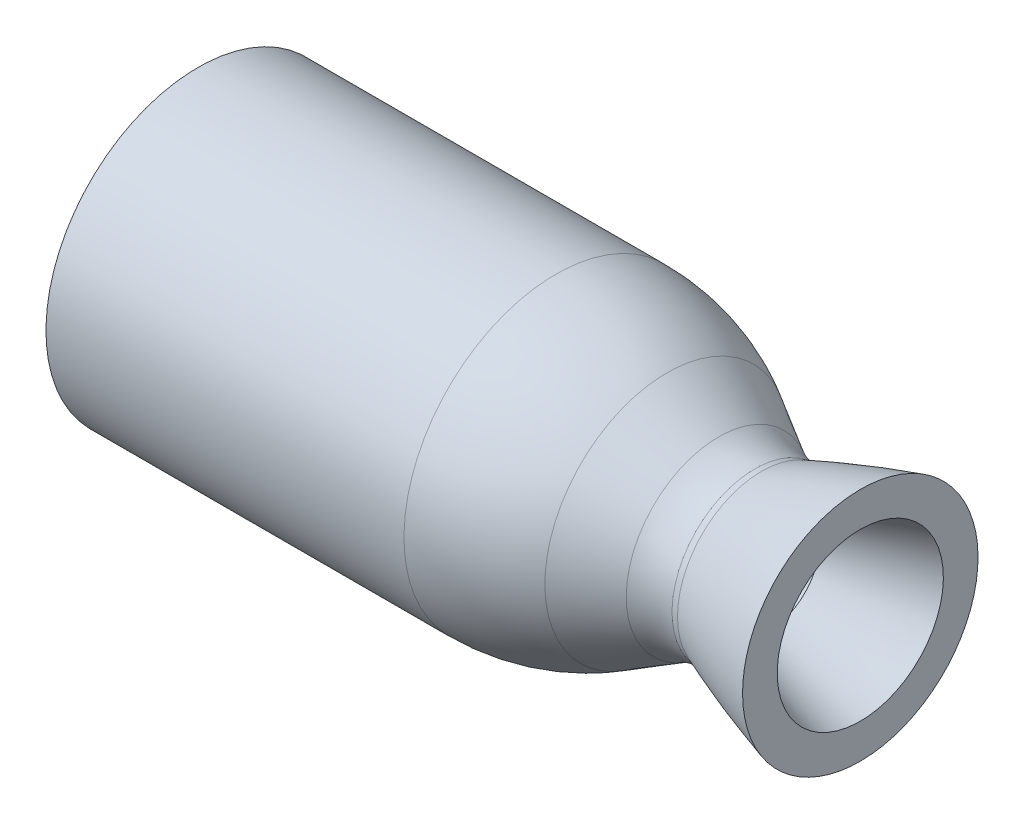
from build123d import *

# Parameters (mm, degrees)
SKETCH1_W = 37.875561449
SKETCH1_H = 61.587456953
SKETCH2_W = 307.951090162
SKETCH2_H = 19.0499659


with BuildPart() as part:
    # Model → Revolve2 (revolve)
    with BuildSketch(Plane.XY):
        with BuildLine():
            Line((37.9852936, 43.0586642), (169.3032936, 43.0586642))
            ThreePointArc((169.3032936, 43.0586642), (190.401848402, 40.280985836), (210.062572, 32.1372484))
            Line((210.062572, 32.1372484), (228.979018864, 21.215832711))
            ThreePointArc((228.979018864, 21.215832711), (235.369964452, 18.568616337), (242.228293864, 17.665700111))
            ThreePointArc((242.228293864, 17.665700111), (243.484699194, 17.783691074), (244.697169154, 18.133537926))
            add(Edge.make_bspline(
                [(244.697169154, 18.133537926), (271.417135664, 28.637280911), (296.809134664, 34.644355511)],
                knots=[0, 0, 0, 1, 1, 1], degree=2))
            Line((296.809134664, 34.644355511), (297.879592264, 34.897593511))
            Line((297.879592264, 34.897593511), (296.809134664, 47.344355511))
            add(Edge.make_bspline(
                [(244.697169154, 30.833537926), (271.417135664, 41.337280911), (296.809134664, 47.344355511)],
                knots=[0, 0, 0, 1, 1, 1], degree=2))
            Line((244.697169154, 30.833537926), (242.228293864, 30.365700111))
            ThreePointArc((242.228293864, 30.365700111), (235.369964452, 31.268616337), (228.979018864, 33.915832711))
            Line((228.979018864, 33.915832711), (210.062572, 44.8372484))
            ThreePointArc((210.062572, 44.8372484), (190.401848402, 52.980985836), (169.3032936, 55.7586642))
            Line((169.3032936, 55.7586642), (37.9852936, 55.7586642))
            Line((37.9852936, 55.7586642), (37.9852936, 43.0586642))
        make_face()
    revolve(axis=Axis((0, -3.5841e-05, 0), (1, 6e-09, 0)))

    # Sketch1 → Cut-Revolve1 (revolve, cut)
    with BuildSketch(Plane.XY):
        with Locations((299.848811079, 30.793694284)):
            Rectangle(SKETCH1_W, SKETCH1_H)
    revolve(axis=Axis((280.911030354, -3.4193e-05, 0), (1, 0, 0)), mode=Mode.SUBTRACT)

    # Sketch2 → Cut-Revolve2 (revolve, cut)
    with BuildSketch(Plane.XY):
        with Locations((153.975545081, 9.52498295)):
            Rectangle(SKETCH2_W, SKETCH2_H)
    revolve(axis=Axis((0, 0, 0), (1, 0, 0)), mode=Mode.SUBTRACT)


solid = part.part
